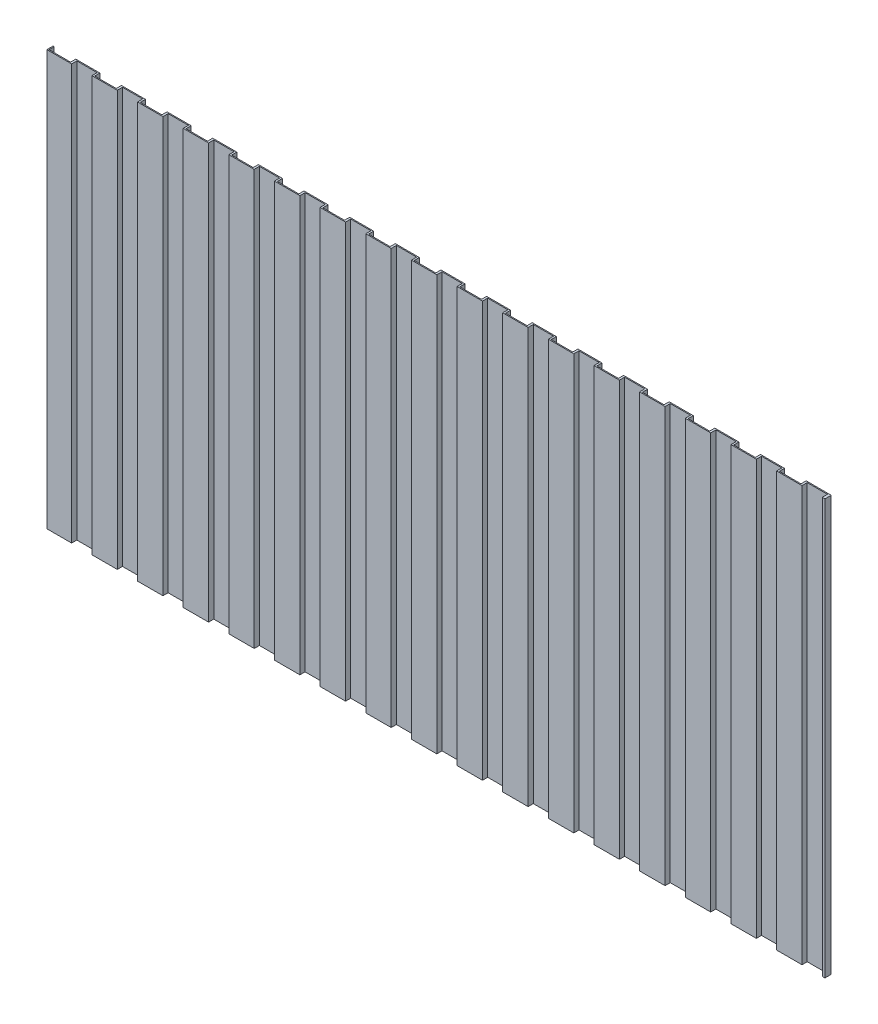
from build123d import *

# Parameters (mm, degrees)
SKETCH1_W           = 7500
SKETCH1_H           = 4000
BOSS_EXTRUDE1_DEPTH = 60
SKETCH2_W           = 208.04993412
SKETCH2_H           = 50
SKETCH2_W_2         = 195.302892205
CUT_EXTRUDE1_DEPTH  = 5107


with BuildPart() as part:
    # Sketch1 → Boss-Extrude1 (new body)
    with BuildSketch(Plane.XY):
        Rectangle(SKETCH1_W, SKETCH1_H)
    extrude(amount=BOSS_EXTRUDE1_DEPTH)

    # Sketch2 → Cut-Extrude1 (cut)
    with BuildSketch(Plane(origin=(0, -2000, 0), x_dir=(-1, 0, 0), z_dir=(0, -1, 0))):
        with Locations((3635.051095731, -25)):
            Rectangle(SKETCH2_W, SKETCH2_H)
        with Locations((3413.343616701, -35)):
            Rectangle(SKETCH2_W_2, SKETCH2_H)
        with Locations((3195.051095731, -25)):
            Rectangle(SKETCH2_W, SKETCH2_H)
        with Locations((2973.343616701, -35)):
            Rectangle(SKETCH2_W_2, SKETCH2_H)
        with Locations((2755.051095731, -25)):
            Rectangle(SKETCH2_W, SKETCH2_H)
        with Locations((2533.343616701, -35)):
            Rectangle(SKETCH2_W_2, SKETCH2_H)
        with Locations((2315.051095731, -25)):
            Rectangle(SKETCH2_W, SKETCH2_H)
        with Locations((2093.343616701, -35)):
            Rectangle(SKETCH2_W_2, SKETCH2_H)
        with Locations((1875.051095731, -25)):
            Rectangle(SKETCH2_W, SKETCH2_H)
        with Locations((1653.343616701, -35)):
            Rectangle(SKETCH2_W_2, SKETCH2_H)
        with Locations((1435.051095731, -25)):
            Rectangle(SKETCH2_W, SKETCH2_H)
        with Locations((1213.343616701, -35)):
            Rectangle(SKETCH2_W_2, SKETCH2_H)
        with Locations((995.051095731, -25)):
            Rectangle(SKETCH2_W, SKETCH2_H)
        with Locations((773.343616701, -35)):
            Rectangle(SKETCH2_W_2, SKETCH2_H)
        with Locations((555.051095731, -25)):
            Rectangle(SKETCH2_W, SKETCH2_H)
        with Locations((333.343616701, -35)):
            Rectangle(SKETCH2_W_2, SKETCH2_H)
        with Locations((115.051095731, -25)):
            Rectangle(SKETCH2_W, SKETCH2_H)
        with Locations((-106.6563833, -35)):
            Rectangle(SKETCH2_W_2, SKETCH2_H)
        with Locations((-324.948904269, -25)):
            Rectangle(SKETCH2_W, SKETCH2_H)
        with Locations((-546.6563833, -35)):
            Rectangle(SKETCH2_W_2, SKETCH2_H)
        with Locations((-764.948904269, -25)):
            Rectangle(SKETCH2_W, SKETCH2_H)
        with Locations((-986.6563833, -35)):
            Rectangle(SKETCH2_W_2, SKETCH2_H)
        with Locations((-1204.948904269, -25)):
            Rectangle(SKETCH2_W, SKETCH2_H)
        with Locations((-1426.6563833, -35)):
            Rectangle(SKETCH2_W_2, SKETCH2_H)
        with Locations((-1644.948904269, -25)):
            Rectangle(SKETCH2_W, SKETCH2_H)
        with Locations((-1866.6563833, -35)):
            Rectangle(SKETCH2_W_2, SKETCH2_H)
        with Locations((-2084.948904269, -25)):
            Rectangle(SKETCH2_W, SKETCH2_H)
        with Locations((-2306.6563833, -35)):
            Rectangle(SKETCH2_W_2, SKETCH2_H)
        with Locations((-2524.948904269, -25)):
            Rectangle(SKETCH2_W, SKETCH2_H)
        with Locations((-2746.6563833, -35)):
            Rectangle(SKETCH2_W_2, SKETCH2_H)
        with Locations((-2964.948904269, -25)):
            Rectangle(SKETCH2_W, SKETCH2_H)
        with Locations((-3186.6563833, -35)):
            Rectangle(SKETCH2_W_2, SKETCH2_H)
        with Locations((-3404.948904269, -25)):
            Rectangle(SKETCH2_W, SKETCH2_H)
        with Locations((-3626.6563833, -35)):
            Rectangle(SKETCH2_W_2, SKETCH2_H)
    extrude(amount=-CUT_EXTRUDE1_DEPTH, mode=Mode.SUBTRACT)


solid = part.part
